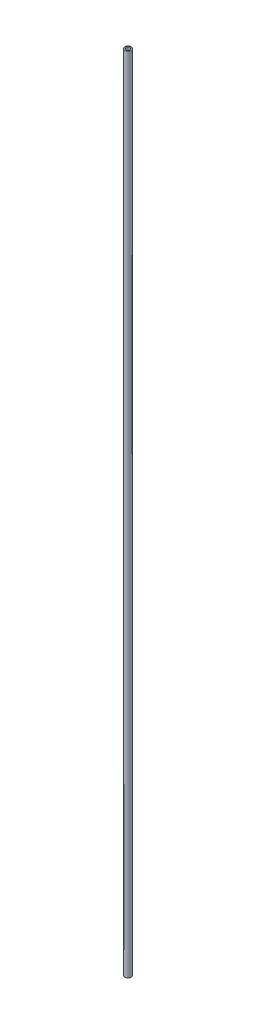
from build123d import *

# Parameters (mm, degrees)
SKETCH1_R                = 9
SKETCH1_R_2              = 6
BOSS_EXTRUDE1_DEPTH      = 2100
BOSS_EXTRUDE1_DEPTH_BACK = 200


with BuildPart() as part:
    # Sketch1 → Boss-Extrude1 (new body, two sides)
    with BuildSketch(Plane(origin=(0, 0, 0), x_dir=(1, 0, 0), z_dir=(0, 1, 0))) as boss_extrude1_sk:
        Circle(SKETCH1_R)
        Circle(SKETCH1_R_2, mode=Mode.SUBTRACT)
    extrude(amount=BOSS_EXTRUDE1_DEPTH)
    extrude(boss_extrude1_sk.sketch, amount=-BOSS_EXTRUDE1_DEPTH_BACK)


solid = part.part
